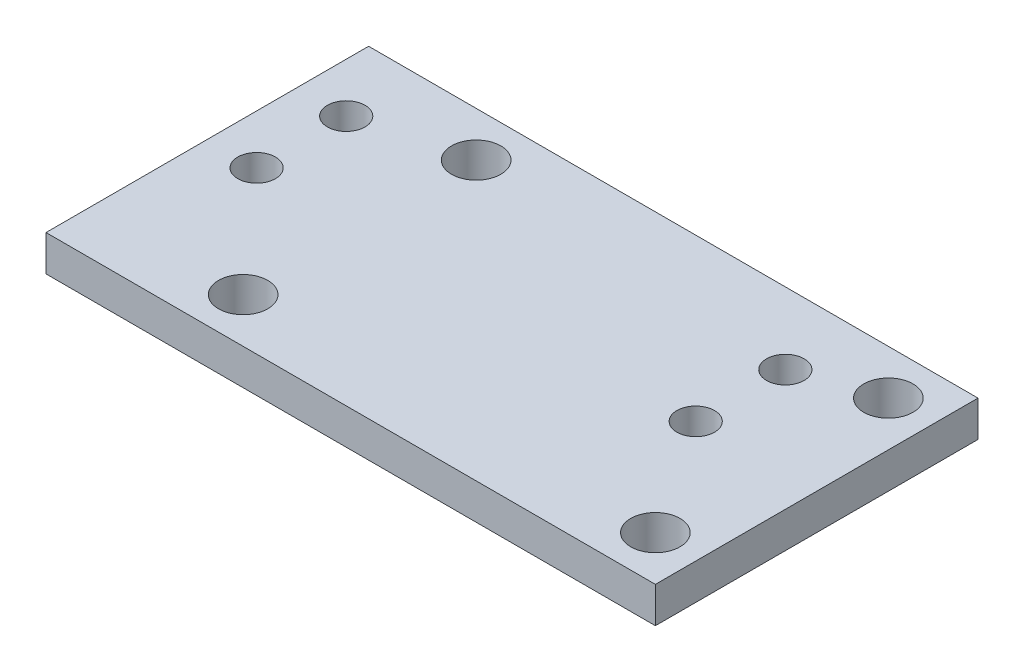
from build123d import *

# Parameters (mm, degrees)
SKETCH_1_R      = 2.75
SKETCH_1_R_2    = 2.1
EXTRUDE_1_DEPTH = 4


with BuildPart() as part:
    # 草图1 → 凸台-拉伸1 (new body)
    with BuildSketch(Plane(origin=(0, 0, 0), x_dir=(1, 0, 0), z_dir=(0, 1, 0))):
        Polygon((-34.919077445, 32.481158859), (21.080922555, 32.481158859), (21.080922555, -3.518841141), (-34.919077445, -3.518841141), (-46.919077445, -3.518841141), (-46.919077445, 32.481158859), align=None)
        with Locations((-29.919077445, 27.481158859)):
            Circle(SKETCH_1_R, mode=Mode.SUBTRACT)
        with Locations((16.080922555, 27.481158859)):
            Circle(SKETCH_1_R, mode=Mode.SUBTRACT)
        with Locations((-29.919077445, 1.481158859)):
            Circle(SKETCH_1_R, mode=Mode.SUBTRACT)
        with Locations((16.080922555, 1.481158859)):
            Circle(SKETCH_1_R, mode=Mode.SUBTRACT)
        with Locations((7.580922555, 14.481158859)):
            Circle(SKETCH_1_R_2, mode=Mode.SUBTRACT)
        with Locations((7.580922555, 24.481158859)):
            Circle(SKETCH_1_R_2, mode=Mode.SUBTRACT)
        with Locations((-41.419077445, 24.481158859)):
            Circle(SKETCH_1_R_2, mode=Mode.SUBTRACT)
        with Locations((-41.419077445, 14.481158859)):
            Circle(SKETCH_1_R_2, mode=Mode.SUBTRACT)
    extrude(amount=EXTRUDE_1_DEPTH)


solid = part.part
